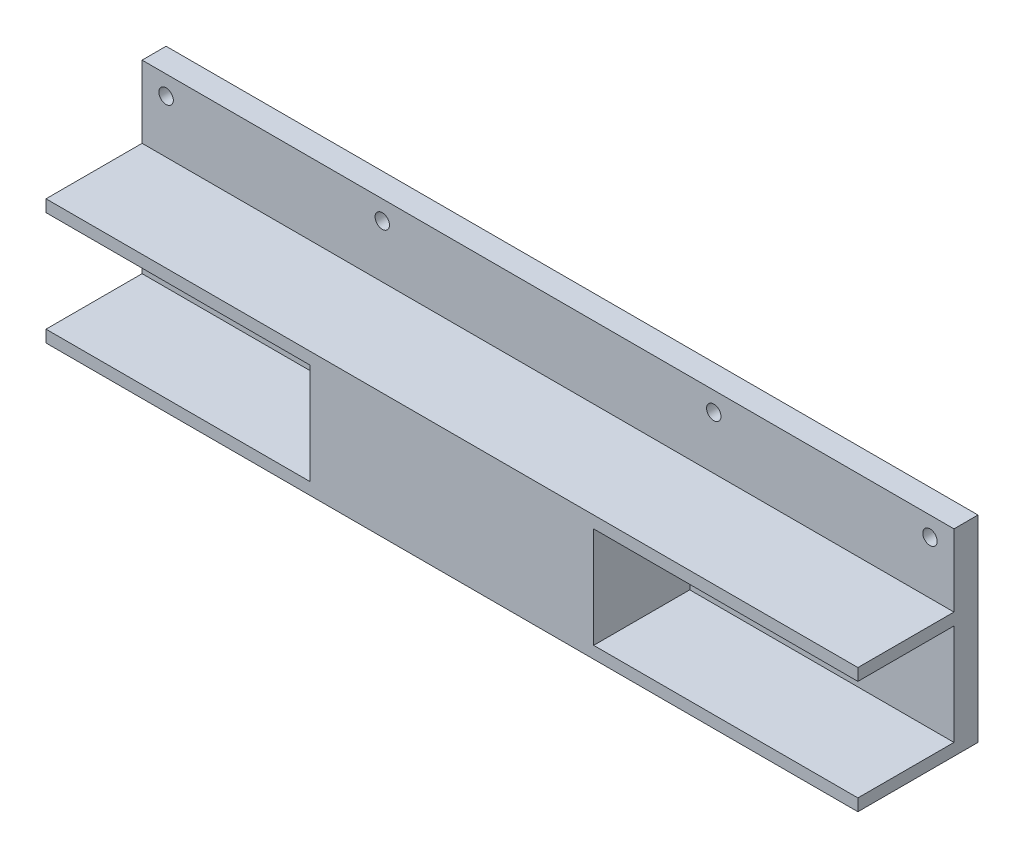
from build123d import *

# Parameters (mm, degrees)
SKETCH_1_W          = 169
SKETCH_1_H          = 41
EXTRUDE_2_DEPTH     = 5
SKETCH_3_R          = 1.5
CUT_EXTRUDE_1_DEPTH = 5
SKETCH_4_W          = 169
SKETCH_4_H          = 26
EXTRUDE_3_DEPTH     = 20
SKETCH_5_W          = 20
SKETCH_5_H          = 21
CUT_EXTRUDE_2_DEPTH = 55
SKETCH_6_W          = 20
SKETCH_6_H          = 21
CUT_EXTRUDE_3_DEPTH = 55


with BuildPart() as part:
    # Эскиз1 → Бобышка-Вытянуть2 (new body)
    with BuildSketch(Plane.XY):
        Rectangle(SKETCH_1_W, SKETCH_1_H)
    extrude(amount=EXTRUDE_2_DEPTH)

    # Эскиз3 → Вырез-Вытянуть1 (cut)
    with BuildSketch(Plane.XY.offset(5)):
        with Locations((79.5, 16.5)):
            Circle(SKETCH_3_R)
        with Locations((34.5, 16.5)):
            Circle(SKETCH_3_R)
        with Locations((-34.5, 16.5)):
            Circle(SKETCH_3_R)
        with Locations((-79.5, 16.5)):
            Circle(SKETCH_3_R)
    extrude(amount=-CUT_EXTRUDE_1_DEPTH, mode=Mode.SUBTRACT)

    # Эскиз4 → Бобышка-Вытянуть3 (add)
    with BuildSketch(Plane.XY.offset(5)):
        with Locations((0, -7.5)):
            Rectangle(SKETCH_4_W, SKETCH_4_H)
    extrude(amount=EXTRUDE_3_DEPTH)

    # Эскиз5 → Вырез-Вытянуть2 (cut)
    with BuildSketch(Plane.ZY.offset(84.5)):
        with Locations((15, -7.5)):
            Rectangle(SKETCH_5_W, SKETCH_5_H)
    extrude(amount=-CUT_EXTRUDE_2_DEPTH, mode=Mode.SUBTRACT)

    # Эскиз6 → Вырез-Вытянуть3 (cut)
    with BuildSketch(Plane(origin=(84.5, 0, 0), x_dir=(0, 0, -1), z_dir=(1, 0, 0))):
        with Locations((-15, -7.5)):
            Rectangle(SKETCH_6_W, SKETCH_6_H)
    extrude(amount=-CUT_EXTRUDE_3_DEPTH, mode=Mode.SUBTRACT)


solid = part.part
